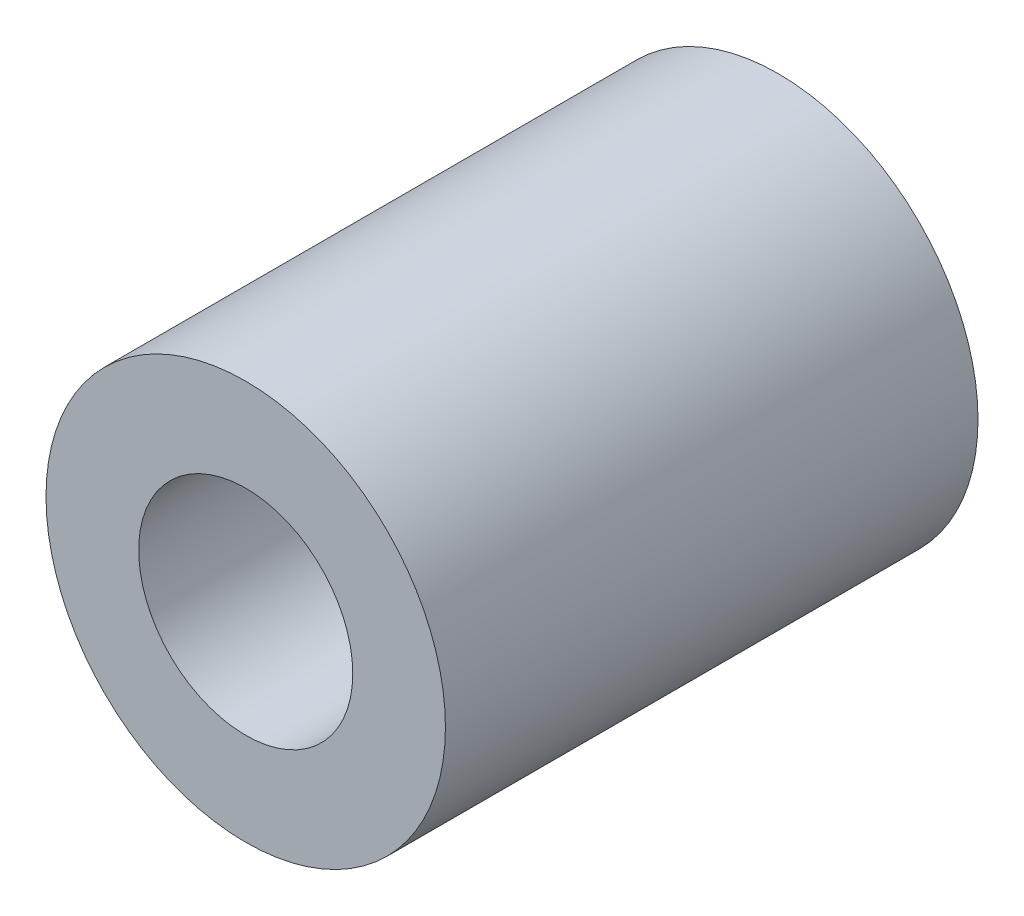
from build123d import *

# Parameters (mm, degrees)
SKETCH1_R           = 4.7625
SKETCH1_R_2         = 2.5527
BOSS_EXTRUDE1_DEPTH = 12.7


with BuildPart() as part:
    # Sketch1 → Boss-Extrude1 (new body)
    with BuildSketch(Plane.XY):
        Circle(SKETCH1_R)
        Circle(SKETCH1_R_2, mode=Mode.SUBTRACT)
    extrude(amount=BOSS_EXTRUDE1_DEPTH)


solid = part.part
